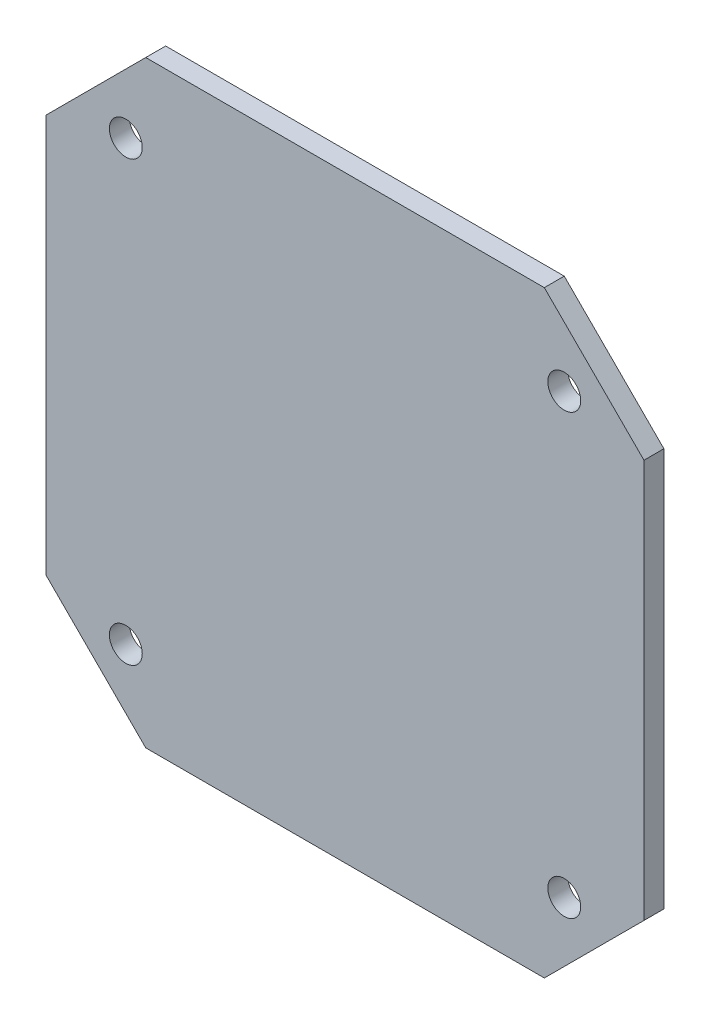
from build123d import *

# Parameters (mm, degrees)
SKETCH_1_W          = 60
SKETCH_1_H          = 60
EXTRUDE_1_DEPTH     = 2
M4X0_7_1_D          = 3.3
M4X0_7_1_DEPTH      = 11.5
M4X0_7_1_TIP        = 0.991420021
CUT_EXTRUDE_1_DEPTH = 80


with BuildPart() as part:
    # ｽｹｯﾁ1 → ﾎﾞｽ - 押し出し1 (new body)
    with BuildSketch(Plane.XY):
        Rectangle(SKETCH_1_W, SKETCH_1_H)
    extrude(amount=EXTRUDE_1_DEPTH)

    # M4x0.7 ねじ穴1
    with Locations(Plane(origin=(22, 22, 0), x_dir=(-1, 0, 0), z_dir=(0, 0, -1))):
        with Locations((0, 0), (0, -44), (44, -44), (44, 0)):
            Hole(M4X0_7_1_D / 2, depth=M4X0_7_1_DEPTH)
            with Locations((0, 0, -(M4X0_7_1_DEPTH + M4X0_7_1_TIP / 2))):  # 118° drill point
                Cone(0, M4X0_7_1_D / 2, M4X0_7_1_TIP, mode=Mode.SUBTRACT)

    # ｽｹｯﾁ4 → ｶｯﾄ - 押し出し1 (cut)
    with BuildSketch(Plane(origin=(0, 0, 0), x_dir=(-1, 0, 0), z_dir=(0, 0, -1))):
        Polygon((-30, -30), (-30, -20), (-20, -30), align=None)
        Polygon((-24.998553068, 25.001446932), (-30, 20), (-30, 30), (-20, 30), align=None)
        Polygon((30, 30), (20, 30), (30, 20), align=None)
        Polygon((30, -30), (30, -20), (20, -30), align=None)
    extrude(amount=-CUT_EXTRUDE_1_DEPTH, mode=Mode.SUBTRACT)


solid = part.part
